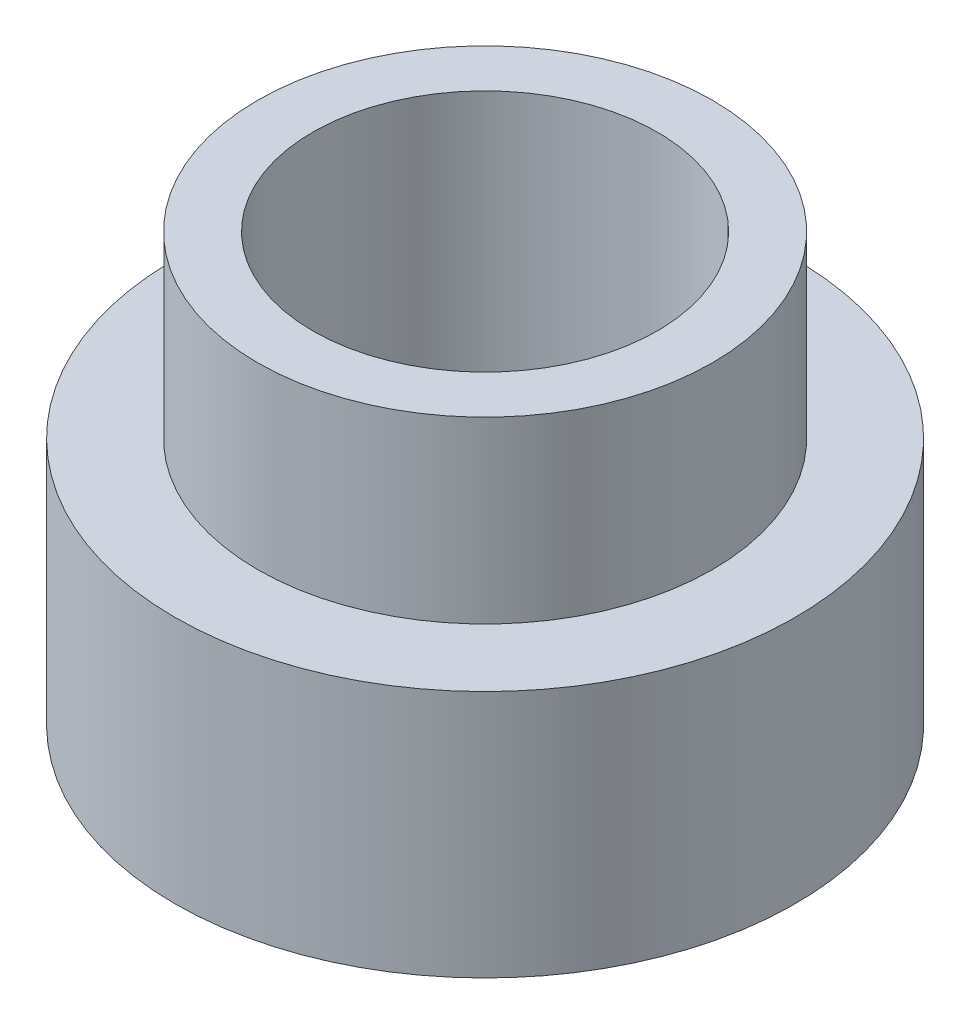
from build123d import *

# Parameters (mm, degrees)
SKETCH1_R           = 2.25
BOSS_EXTRUDE1_DEPTH = 3.1
SKETCH2_OUTSIDE_W   = 7.916
SKETCH2_OUTSIDE_H   = 7.916
SKETCH2_OUTSIDE_R   = 1.65
CUT_EXTRUDE1_DEPTH  = 1.3
SKETCH3_R           = 1.25
CUT_EXTRUDE2_DEPTH  = 4.1


with BuildPart() as part:
    # Sketch1 → Boss-Extrude1 (new body)
    with BuildSketch(Plane(origin=(0, 0, 0), x_dir=(1, 0, 0), z_dir=(0, 1, 0))):
        Circle(SKETCH1_R)
    extrude(amount=BOSS_EXTRUDE1_DEPTH)

    # Sketch2 outside → Cut-Extrude1 (cut)
    with BuildSketch(Plane(origin=(0, 3.1, 0), x_dir=(1, 0, 0), z_dir=(0, 1, 0))):
        Rectangle(SKETCH2_OUTSIDE_W, SKETCH2_OUTSIDE_H)
        Circle(SKETCH2_OUTSIDE_R, mode=Mode.SUBTRACT)
    extrude(amount=-CUT_EXTRUDE1_DEPTH, mode=Mode.SUBTRACT)

    # Sketch3 → Cut-Extrude2 (cut, through all)
    with BuildSketch(Plane(origin=(0, 3.1, 0), x_dir=(1, 0, 0), z_dir=(0, 1, 0))):
        Circle(SKETCH3_R)
    extrude(amount=-CUT_EXTRUDE2_DEPTH, mode=Mode.SUBTRACT)


solid = part.part
